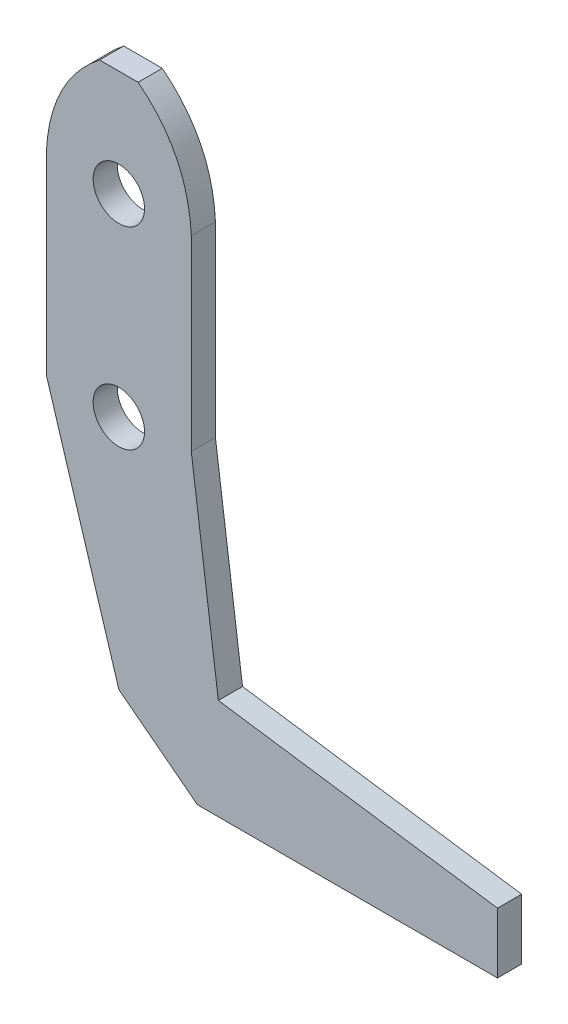
from build123d import *

# Parameters (mm, degrees)
SKETCH1_R           = 3.3782
BOSS_EXTRUDE1_DEPTH = 3.175


with BuildPart() as part:
    # Sketch1 → Boss-Extrude1 (new body)
    with BuildSketch(Plane.XY):
        with BuildLine():
            Line((-2.54, 39.37), (2.54, 39.37))
            add(Edge.make_bspline(
                [(2.54, 39.37), (9.095418915, 34.201637521), (9.525, 25.4)],
                knots=[0, 0, 0, 1, 1, 1], degree=2))
            Line((9.525, 25.4), (9.525, 0.833077402))
            Line((9.525, 0.833077402), (13.080713372, -25.725670045))
            Line((13.080713372, -25.725670045), (49.772779476, -31.025635149))
            Line((49.772779476, -31.025635149), (49.772779476, -38.975582805))
            Line((49.772779476, -38.975582805), (10.326960053, -38.975582805))
            Line((10.326960053, -38.975582805), (0, -31.025635149))
            Line((0, -31.025635149), (-9.525, 0))
            Line((-9.525, 0), (-9.525, 25.4))
            add(Edge.make_bspline(
                [(-2.54, 39.37), (-9.095418915, 34.201637521), (-9.525, 25.4)],
                knots=[0, 0, 0, 1, 1, 1], degree=2))
        make_face()
        with Locations((0, 25.4)):
            Circle(SKETCH1_R, mode=Mode.SUBTRACT)
        Circle(SKETCH1_R, mode=Mode.SUBTRACT)
    extrude(amount=BOSS_EXTRUDE1_DEPTH)


solid = part.part
